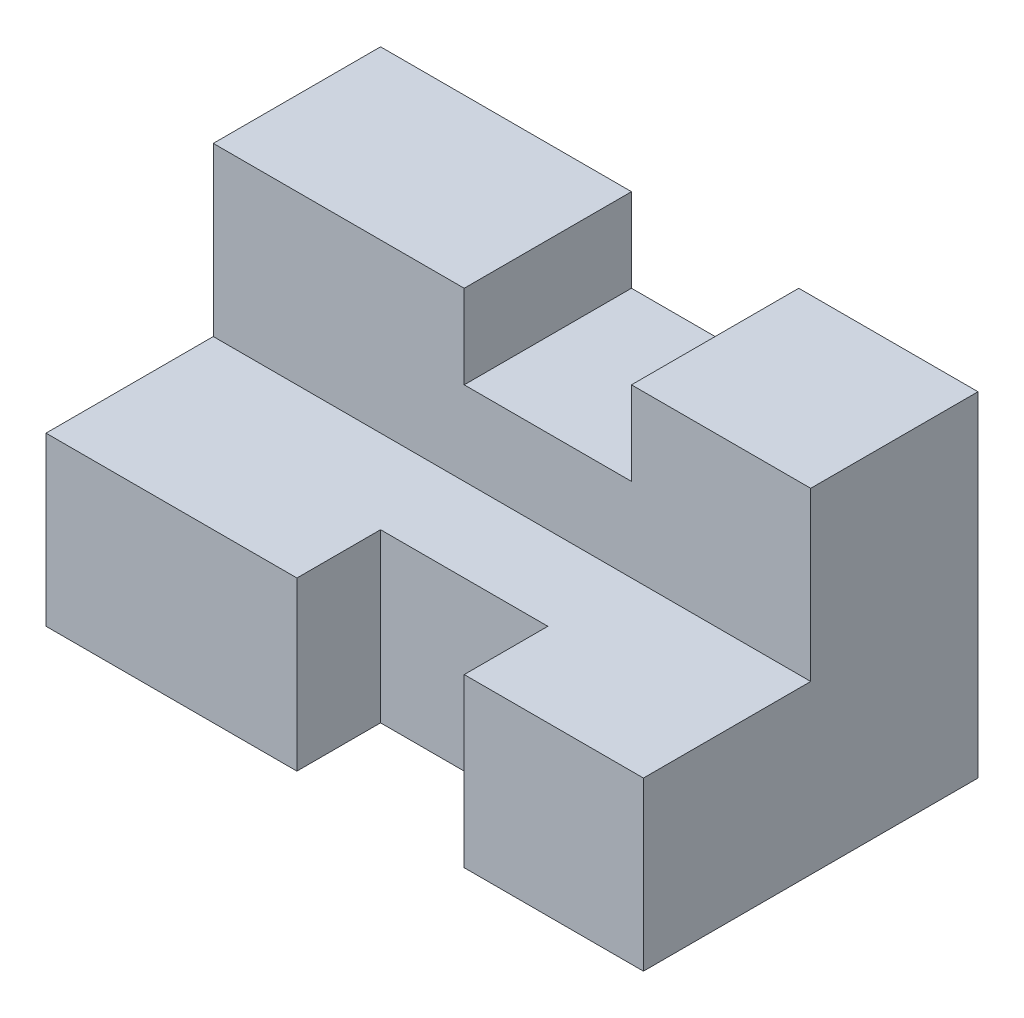
from build123d import *

# Parameters (mm, degrees)
BOSS_EXTRUDE1_DEPTH = 25
CUT_EXTRUDE1_REACH  = 16
SKETCH3_W           = 14
SKETCH3_H           = 7


with BuildPart() as part:
    # Sketch2 → Boss-Extrude1 (new body, symmetric)
    with BuildSketch(Plane(origin=(0, 0, 0), x_dir=(0, 0, -1), z_dir=(1, 0, 0))):
        Polygon((0, 0), (-28, 0), (-28, 14), (-14, 14), align=None)
    extrude(amount=BOSS_EXTRUDE1_DEPTH, both=True)

    # Sketch3 → Cut-Extrude1 (cut, up to next)
    with BuildSketch(Plane(origin=(0, 14, 0), x_dir=(1, 0, 0), z_dir=(0, 1, 0)), mode=Mode.PRIVATE) as cut_extrude1_sk1:
        with Locations((3, -24.5)):
            Rectangle(SKETCH3_W, SKETCH3_H)
    cut_extrude1_tool1 = extrude(cut_extrude1_sk1.sketch, amount=-CUT_EXTRUDE1_REACH, mode=Mode.PRIVATE) & part.part
    add(cut_extrude1_tool1.solids().sort_by_distance((3, 14, 24.5))[0], mode=Mode.SUBTRACT)

    # Mirror1: part across plane


with BuildPart() as part_1:
    add(part.part)
    add(part.part.mirror(Plane(origin=(25, 14, 14), x_dir=(0, 0.707106781, 0.707106781), z_dir=(0, -0.707106781, 0.707106781))))


solid = part_1.part
